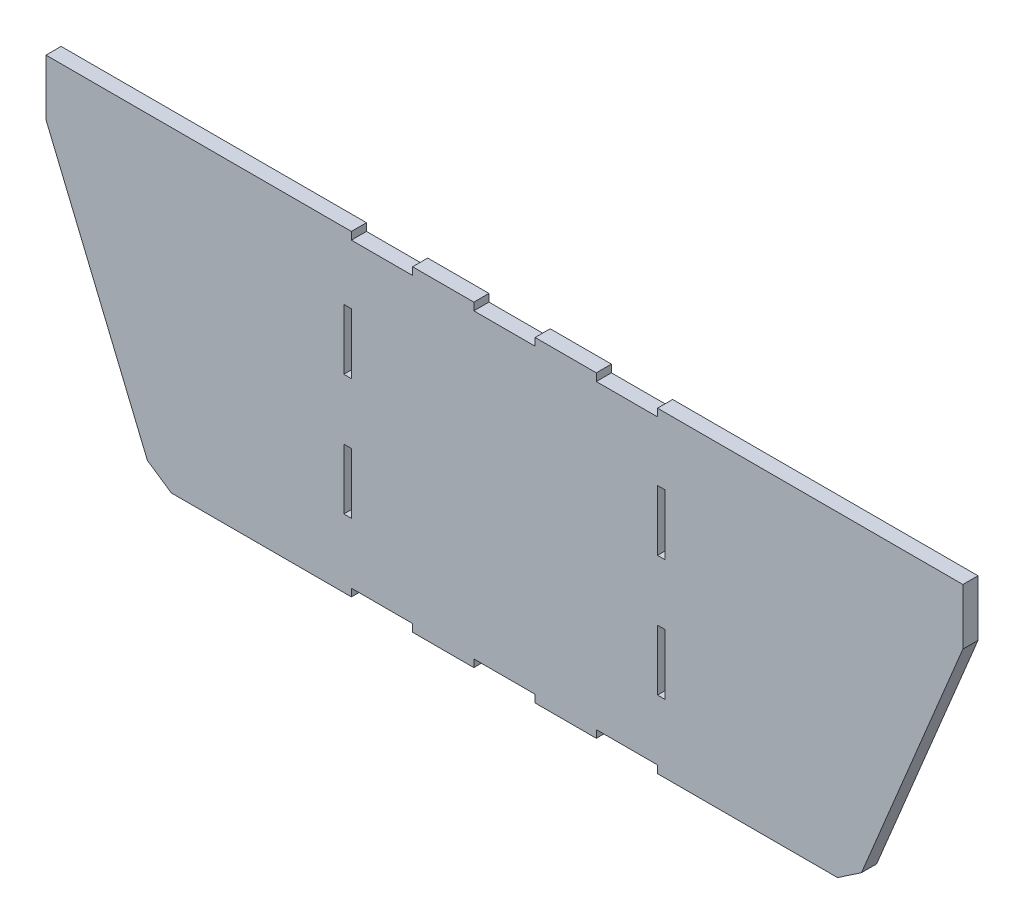
from build123d import *

# Parameters (mm, degrees)
BOSS_EXTRUDE1_DEPTH = 20.32
SKETCH2_W           = 10.166490401
SKETCH2_H           = 81.316938585
SKETCH2_W_2         = 10.166490402
SKETCH2_H_2         = 81.316938584
SKETCH2_W_3         = 82.271298803
SKETCH2_H_3         = 10.16
CUT_EXTRUDE2_DEPTH  = 137.414
CUT_EXTRUDE3_DEPTH  = 21.3200001
SKETCH5_W           = 82.296
SKETCH5_H           = 10.16
CUT_EXTRUDE4_DEPTH  = 21.3200001
CUT_EXTRUDE5_DEPTH  = 21.3200001


with BuildPart() as part:
    # Sketch1 → Boss-Extrude1 (new body)
    with BuildSketch(Plane.XY):
        with BuildLine():
            Line((0, 0), (1345.447057269, 0))
            Line((1345.447057269, 0), (1156.937235756, -454.288839135))
            add(Edge.make_bspline(
                [(1156.937235756, -454.288839135), (1155.965204773, -456.631331547), (1154.630956054, -458.816896883), (1152.225947859, -461.69350105), (1151.355065983, -462.590813772), (1149.473312624, -464.260936999), (1148.45987476, -465.033112958), (1146.360299176, -466.401155283), (1145.26635201, -467.004685932), (1142.990856866, -468.052074807), (1141.798989191, -468.498505895), (1138.174492983, -469.560599459), (1135.699262078, -469.911644948), (1133.16419506, -469.9)],
                knots=[0, 0, 0, 0, 0.25, 0.25, 0.375, 0.375, 0.5, 0.5, 0.625, 0.625, 0.75, 0.75, 1, 1, 1, 1], degree=3))
            Line((1133.16419506, -469.9), (212.282862208, -469.9))
            add(Edge.make_bspline(
                [(188.509821513, -454.288839135), (189.481852496, -456.631331547), (190.816101215, -458.816896883), (193.22110941, -461.69350105), (194.091991286, -462.590813772), (195.973744645, -464.260936999), (196.987182509, -465.033112958), (199.086758093, -466.401155283), (200.180705259, -467.004685932), (202.456200403, -468.052074807), (203.648068078, -468.498505895), (207.272564286, -469.560599459), (209.747795191, -469.911644948), (212.282862208, -469.9)],
                knots=[0, 0, 0, 0, 0.25, 0.25, 0.375, 0.375, 0.5, 0.5, 0.625, 0.625, 0.75, 0.75, 1, 1, 1, 1], degree=3))
            Line((188.509821513, -454.288839135), (0, 0))
        make_face()
    extrude(amount=BOSS_EXTRUDE1_DEPTH)

    # Sketch2 → Cut-Extrude2 (cut)
    with BuildSketch(Plane.XY.offset(20.32)):
        with Locations((461.924984631, -337.764592123)):
            Rectangle(SKETCH2_W, SKETCH2_H)
        with Locations((883.522072638, -337.764592123)):
            Rectangle(SKETCH2_W_2, SKETCH2_H)
        with Locations((883.522072638, -175.130714953)):
            Rectangle(SKETCH2_W_2, SKETCH2_H_2)
        with Locations((461.924984631, -175.130714953)):
            Rectangle(SKETCH2_W, SKETCH2_H_2)
        with Locations((837.303178036, -464.82)):
            Rectangle(SKETCH2_W_3, SKETCH2_H_3)
        with Locations((672.723528635, -464.82)):
            Rectangle(SKETCH2_W_3, SKETCH2_H_3)
        with Locations((508.143879233, -464.82)):
            Rectangle(SKETCH2_W_3, SKETCH2_H_3)
    extrude(amount=-CUT_EXTRUDE2_DEPTH, mode=Mode.SUBTRACT)

    # Sketch4 → Cut-Extrude3 (cut, through all)
    with BuildSketch(Plane.XY.offset(20.32)):
        Polygon((0, 0), (1345.447057269, 0), (1327.002268746, -44.45), (18.444788523, -44.45), align=None)
    extrude(amount=-CUT_EXTRUDE3_DEPTH, mode=Mode.SUBTRACT)

    # Sketch5 → Cut-Extrude4 (cut, through all)
    with BuildSketch(Plane.XY.offset(20.32)):
        with Locations((508.131528634, -49.53)):
            Rectangle(SKETCH5_W, SKETCH5_H)
        with Locations((672.723528634, -49.53)):
            Rectangle(SKETCH5_W, SKETCH5_H)
        with Locations((837.315528634, -49.53)):
            Rectangle(SKETCH5_W, SKETCH5_H)
    extrude(amount=-CUT_EXTRUDE4_DEPTH, mode=Mode.SUBTRACT)

    # Sketch6 → Cut-Extrude5 (cut, through all)
    with BuildSketch(Plane.XY.offset(20.32)):
        Polygon((192.807539001, -448.077869782), (224.982862208, -469.9), (232.080223429, -549.766419732), (-59.510742861, -242.335130221), (-120.238907144, 37.382474964), (56.544788523, -44.45), (56.544788523, -119.698975594), align=None)
        Polygon((1120.46419506, -469.9), (1113.36683384, -549.766419732), (1404.95780013, -242.335130221), (1465.685964413, 37.382474964), (1288.902268746, -44.45), (1288.902268746, -119.698975594), (1152.639518267, -448.077869782), align=None)
    extrude(amount=-CUT_EXTRUDE5_DEPTH, mode=Mode.SUBTRACT)


solid = part.part
